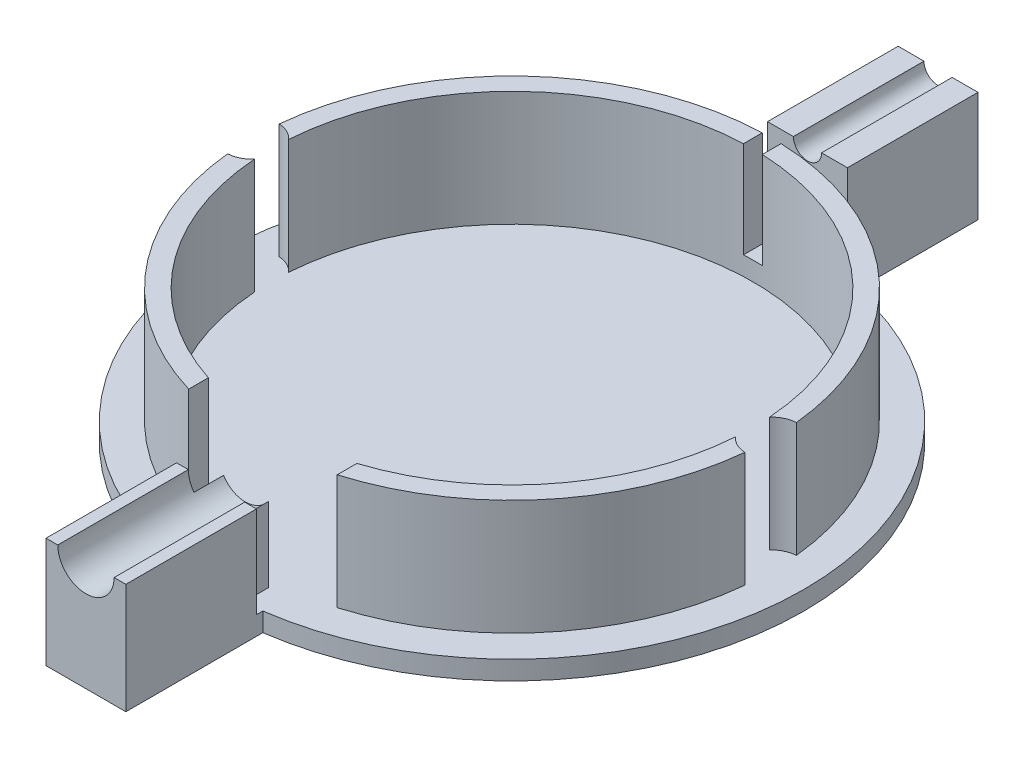
from build123d import *

# Parameters (mm, degrees)
SKETCH1_R                = 31.06
BOSS_EXTRUDE1_DEPTH      = 2
SKETCH2_R                = 27.66
SKETCH2_R_2              = 25.66
BOSS_EXTRUDE2_DEPTH      = 12.25
CUT_EXTRUDE1_DEPTH       = 12.25
CUT_EXTRUDE2_DEPTH       = 6.8
BOSS_EXTRUDE5_DEPTH      = 12.25
CUT_EXTRUDE3_DEPTH       = 7.6
SKETCH9_W                = 2
SKETCH9_H                = 2
SKETCH9_H_2              = 8.25
CUT_EXTRUDE4_DEPTH       = 32.06
CUT_EXTRUDE5_DEPTH       = 12.25
SKETCH12_W               = 4.25
SKETCH12_H               = 14.29
SKETCH12_R               = 31.06
BOSS_EXTRUDE7_DEPTH      = 2
BOSS_EXTRUDE8_DEPTH      = 13.9
BOSS_EXTRUDE9_DEPTH      = 2
BOSS_EXTRUDE9_DEPTH_BACK = 2
BOSS_EXTRUDE10_DEPTH     = 13.9


with BuildPart() as part:
    # Sketch1 → Boss-Extrude1 (new body)
    with BuildSketch(Plane(origin=(0, 0, 0), x_dir=(1, 0, 0), z_dir=(0, 1, 0))):
        Circle(SKETCH1_R)
    extrude(amount=BOSS_EXTRUDE1_DEPTH)

    # Sketch2 → Boss-Extrude2 (add)
    with BuildSketch(Plane(origin=(0, 2, 0), x_dir=(1, 0, 0), z_dir=(0, 1, 0))):
        Circle(SKETCH2_R)
        Circle(SKETCH2_R_2, mode=Mode.SUBTRACT)
    extrude(amount=BOSS_EXTRUDE2_DEPTH)

    # Sketch4 → Cut-Extrude1 (cut)
    with BuildSketch(Plane(origin=(0, 14.25, 0), x_dir=(1, 0, 0), z_dir=(0, 1, 0))):
        with BuildLine():
            ThreePointArc((25.66, 0), (25.643895434, -0.90897027), (25.595601952, -1.816799576))
            ThreePointArc((25.595601952, -1.816799576), (26.465284353, -2.476924408), (27.523295372, -2.746600052))
            ThreePointArc((27.523295372, -2.746600052), (27.625802703, -1.375), (27.66, 0))
            ThreePointArc((27.66, 0), (27.625802703, 1.375), (27.523295372, 2.746600052))
            ThreePointArc((27.523295372, 2.746600052), (26.465284353, 2.476924408), (25.595601952, 1.816799576))
            ThreePointArc((25.595601952, 1.816799576), (25.643895434, 0.90897027), (25.66, 0))
        make_face()
        with BuildLine():
            ThreePointArc((-25.595601952, 1.816799576), (-25.66, 0), (-25.595601952, -1.816799576))
            ThreePointArc((-25.595601952, -1.816799576), (-26.465284353, -2.476924408), (-27.523295372, -2.746600052))
            ThreePointArc((-27.523295372, -2.746600052), (-27.66, 0), (-27.523295372, 2.746600052))
            ThreePointArc((-27.523295372, 2.746600052), (-26.465284353, 2.476924408), (-25.595601952, 1.816799576))
        make_face()
    extrude(amount=-CUT_EXTRUDE1_DEPTH, mode=Mode.SUBTRACT)

    # Sketch5 → Cut-Extrude2 (cut)
    with BuildSketch(Plane(origin=(0, 14.25, 0), x_dir=(1, 0, 0), z_dir=(0, 1, 0))):
        with BuildLine():
            Line((0, -27.66), (0, -25.66))
            ThreePointArc((0, -25.66), (-1.502578344, -25.615968815), (-3, -25.484026369))
            Line((-3, -25.484026369), (-3, -27.496828908))
            ThreePointArc((-3, -27.496828908), (-1.502217095, -27.619177102), (0, -27.66))
        make_face()
        with BuildLine():
            ThreePointArc((3, -25.484026369), (1.502578344, -25.615968815), (0, -25.66))
            Line((0, -25.66), (0, -27.66))
            ThreePointArc((0, -27.66), (1.502217095, -27.619177102), (3, -27.496828908))
            Line((3, -27.496828908), (3, -25.484026369))
        make_face()
    extrude(amount=-CUT_EXTRUDE2_DEPTH, mode=Mode.SUBTRACT)

    # Sketch7 → Boss-Extrude5 (add)
    with BuildSketch(Plane(origin=(0, 2, 0), x_dir=(1, 0, 0), z_dir=(0, 1, 0))):
        with BuildLine():
            Line((2.4, -28.301441659), (2.4, -30.96713742))
            ThreePointArc((2.4, -30.96713742), (0, -31.06), (-2.4, -30.96713742))
            Line((-2.4, -30.96713742), (-2.4, -28.301441659))
            ThreePointArc((-2.4, -28.301441659), (0, -28.402816869), (2.4, -28.301441659))
        make_face()
    extrude(amount=BOSS_EXTRUDE5_DEPTH)

    # Sketch8 → Cut-Extrude3 (cut)
    with BuildSketch(Plane.XY.offset(31.06)):
        with BuildLine():
            ThreePointArc((2.4, 13.55), (2.059119927, 13.931748181), (1.658312395, 14.25))
            Line((1.658312395, 14.25), (-1.658312395, 14.25))
            ThreePointArc((-1.658312395, 14.25), (-2.059119927, 13.931748181), (-2.4, 13.55))
            Line((-2.4, 13.55), (-2.4, 11.75))
            Line((-2.4, 11.75), (2.4, 11.75))
            Line((2.4, 11.75), (2.4, 13.55))
        make_face()
        with BuildLine():
            ThreePointArc((3, 11.75), (2.846049894, 12.698683298), (2.4, 13.55))
            Line((2.4, 13.55), (2.4, 11.75))
            Line((2.4, 11.75), (2.4, 9.95))
            ThreePointArc((2.4, 9.95), (2.846049894, 10.801316702), (3, 11.75))
        make_face()
        with BuildLine():
            Line((2.4, 9.95), (2.4, 11.75))
            Line((2.4, 11.75), (-2.4, 11.75))
            Line((-2.4, 11.75), (-2.4, 9.95))
            ThreePointArc((-2.4, 9.95), (0, 8.75), (2.4, 9.95))
        make_face()
        with BuildLine():
            Line((-2.4, 11.75), (-2.4, 13.55))
            ThreePointArc((-2.4, 13.55), (-3, 11.75), (-2.4, 9.95))
            Line((-2.4, 9.95), (-2.4, 11.75))
        make_face()
        with BuildLine():
            Line((2.4, 13.55), (2.4, 14.25))
            Line((2.4, 14.25), (1.658312395, 14.25))
            ThreePointArc((1.658312395, 14.25), (2.059119927, 13.931748181), (2.4, 13.55))
        make_face()
        with BuildLine():
            ThreePointArc((-2.4, 13.55), (-2.059119927, 13.931748181), (-1.658312395, 14.25))
            Line((-1.658312395, 14.25), (-2.4, 14.25))
            Line((-2.4, 14.25), (-2.4, 13.55))
        make_face()
    extrude(amount=-CUT_EXTRUDE3_DEPTH, mode=Mode.SUBTRACT)

    # Sketch9 → Cut-Extrude4 (cut, through all)
    with BuildSketch(Plane.XY):
        with Locations((0, 5)):
            Rectangle(SKETCH9_W, SKETCH9_H)
        with Locations((0, 10.125)):
            Rectangle(SKETCH9_W, SKETCH9_H_2)
    extrude(amount=-CUT_EXTRUDE4_DEPTH, mode=Mode.SUBTRACT)

    # Sketch11 → Cut-Extrude5 (cut)
    with BuildSketch(Plane(origin=(0, 14.25, 0), x_dir=(1, 0, 0), z_dir=(0, 1, 0))):
        with BuildLine():
            ThreePointArc((3, -27.496828908), (5.472387467, -27.113254607), (7.9, -26.50784035))
            Line((7.9, -26.50784035), (7.9, -24.413635534))
            ThreePointArc((7.9, -24.413635534), (5.476215311, -25.068838542), (3, -25.484026369))
            Line((3, -25.484026369), (3, -27.496828908))
        make_face()
        with BuildLine():
            Line((-7.9, -26.50784035), (-7.9, -27.987377494))
            Line((-7.9, -27.987377494), (7.9, -27.987377494))
            Line((7.9, -27.987377494), (7.9, -26.50784035))
            ThreePointArc((7.9, -26.50784035), (5.472387467, -27.113254607), (3, -27.496828908))
            Line((3, -27.496828908), (3, -25.484026369))
            ThreePointArc((3, -25.484026369), (5.476215311, -25.068838542), (7.9, -24.413635534))
            Line((7.9, -24.413635534), (7.9, -24.165769621))
            Line((7.9, -24.165769621), (-7.9, -24.165769621))
            Line((-7.9, -24.165769621), (-7.9, -24.413635534))
            ThreePointArc((-7.9, -24.413635534), (-5.476215311, -25.068838542), (-3, -25.484026369))
            Line((-3, -25.484026369), (-3, -27.496828908))
            ThreePointArc((-3, -27.496828908), (-5.472387467, -27.113254607), (-7.9, -26.50784035))
        make_face()
        with BuildLine():
            Line((-7.9, -24.413635534), (-7.9, -26.50784035))
            ThreePointArc((-7.9, -26.50784035), (-5.472387467, -27.113254607), (-3, -27.496828908))
            Line((-3, -27.496828908), (-3, -25.484026369))
            ThreePointArc((-3, -25.484026369), (-5.476215311, -25.068838542), (-7.9, -24.413635534))
        make_face()
    extrude(amount=-CUT_EXTRUDE5_DEPTH, mode=Mode.SUBTRACT)

    # Sketch12 → Boss-Extrude7 (add)
    with BuildSketch(Plane.XZ):
        with Locations((2.125, 38.205)):
            Rectangle(SKETCH12_W, SKETCH12_H)
        with Locations((-2.125, 38.205)):
            Rectangle(SKETCH12_W, SKETCH12_H)
        with BuildLine():
            Line((4.25, 31.06), (0, 31.06))
            ThreePointArc((0, 31.06), (2.130014484, 30.986878486), (4.25, 30.767858229))
            Line((4.25, 30.767858229), (4.25, 31.06))
        make_face()
        with BuildLine():
            ThreePointArc((-4.25, 30.767858229), (-2.130014484, 30.986878486), (0, 31.06))
            Line((0, 31.06), (-4.25, 31.06))
            Line((-4.25, 31.06), (-4.25, 30.767858229))
        make_face()
        with Locations((2.125, -38.205)):
            Rectangle(SKETCH12_W, SKETCH12_H)
        with Locations((-2.125, -38.205)):
            Rectangle(SKETCH12_W, SKETCH12_H)
        with BuildLine():
            ThreePointArc((0, -31.06), (-2.130014484, -30.986878486), (-4.25, -30.767858229))
            Line((-4.25, -30.767858229), (-4.25, -31.06))
            Line((-4.25, -31.06), (0, -31.06))
        make_face()
        with BuildLine():
            Line((4.25, -31.06), (4.25, -30.767858229))
            ThreePointArc((4.25, -30.767858229), (2.130014484, -30.986878486), (0, -31.06))
            Line((0, -31.06), (4.25, -31.06))
        make_face()
        Circle(SKETCH12_R)
    extrude(amount=-BOSS_EXTRUDE7_DEPTH)

    # Sketch13 → Boss-Extrude8 (add)
    with BuildSketch(Plane.XY.offset(45.35)):
        with BuildLine():
            Line((-3, 11.75), (-4.25, 11.75))
            Line((-4.25, 11.75), (-4.25, 2))
            Line((-4.25, 2), (4.25, 2))
            Line((4.25, 2), (4.25, 11.75))
            Line((4.25, 11.75), (3, 11.75))
            ThreePointArc((3, 11.75), (0, 8.75), (-3, 11.75))
        make_face()
    extrude(amount=-BOSS_EXTRUDE8_DEPTH)

    # Sketch14 → Boss-Extrude9 (add, two sides)
    with BuildSketch(Plane.XY.offset(31.06)) as boss_extrude9_sk:
        with BuildLine():
            Line((-2.4, 2), (2.4, 2))
            Line((2.4, 2), (2.4, 9.95))
            ThreePointArc((2.4, 9.95), (0, 8.75), (-2.4, 9.95))
            Line((-2.4, 9.95), (-2.4, 2))
        make_face()
    extrude(amount=BOSS_EXTRUDE9_DEPTH)
    extrude(boss_extrude9_sk.sketch, amount=-BOSS_EXTRUDE9_DEPTH_BACK)

    # Sketch15 → Boss-Extrude10 (add)
    with BuildSketch(Plane(origin=(0, 0, -45.35), x_dir=(-1, 0, 0), z_dir=(0, 0, -1))):
        with BuildLine():
            Line((-1.5, 11.75), (-4.25, 11.75))
            Line((-4.25, 11.75), (-4.25, 0))
            Line((-4.25, 0), (4.25, 0))
            Line((4.25, 0), (4.25, 11.75))
            Line((4.25, 11.75), (1.5, 11.75))
            ThreePointArc((1.5, 11.75), (0, 10.25), (-1.5, 11.75))
        make_face()
    extrude(amount=-BOSS_EXTRUDE10_DEPTH)


solid = part.part
